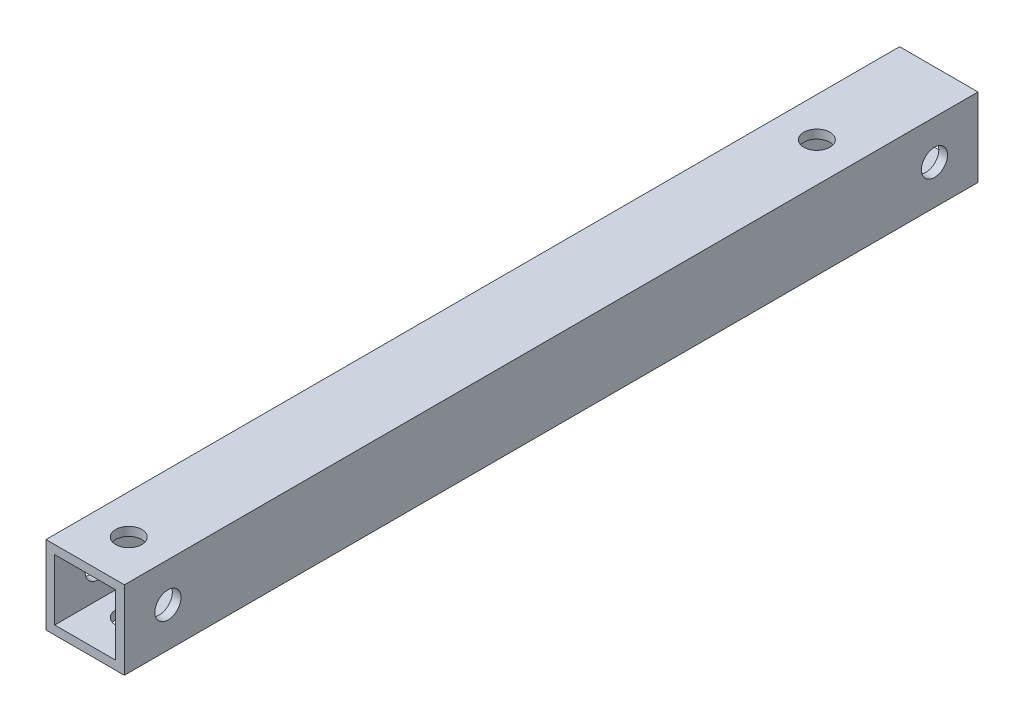
from build123d import *

# Parameters (mm, degrees)
SKETCH_1_W          = 9
SKETCH_1_H          = 9
EXTRUDE_1_DEPTH     = 98
SKETCH_2_W          = 7
SKETCH_2_H          = 7
CUT_EXTRUDE_1_DEPTH = 106.6
SKETCH_3_R          = 1.5
CUT_EXTRUDE_2_DEPTH = 106.6
SKETCH_4_R          = 1.5
CUT_EXTRUDE_4_DEPTH = 50


with BuildPart() as part:
    # ｽｹｯﾁ1 → ﾎﾞｽ - 押し出し1 (new body)
    with BuildSketch(Plane.XY):
        Rectangle(SKETCH_1_W, SKETCH_1_H)
    extrude(amount=EXTRUDE_1_DEPTH)

    # ｽｹｯﾁ2 → ｶｯﾄ - 押し出し1 (cut)
    with BuildSketch(Plane.XY.offset(98)):
        Rectangle(SKETCH_2_W, SKETCH_2_H)
    extrude(amount=-CUT_EXTRUDE_1_DEPTH, mode=Mode.SUBTRACT)

    # ｽｹｯﾁ3 → ｶｯﾄ - 押し出し2 (cut)
    with BuildSketch(Plane(origin=(0, 4.5, 0), x_dir=(1, 0, 0), z_dir=(0, 1, 0))):
        with Locations((0, -93)):
            Circle(SKETCH_3_R)
        with Locations((0, -14)):
            Circle(SKETCH_3_R)
    extrude(amount=-CUT_EXTRUDE_2_DEPTH, mode=Mode.SUBTRACT)

    # ｽｹｯﾁ4 → ｶｯﾄ - 押し出し4 (cut)
    with BuildSketch(Plane.ZY.offset(4.5)):
        with Locations((5, 0)):
            Circle(SKETCH_4_R)
        with Locations((93, 0)):
            Circle(SKETCH_4_R)
    extrude(amount=-CUT_EXTRUDE_4_DEPTH, mode=Mode.SUBTRACT)


solid = part.part
